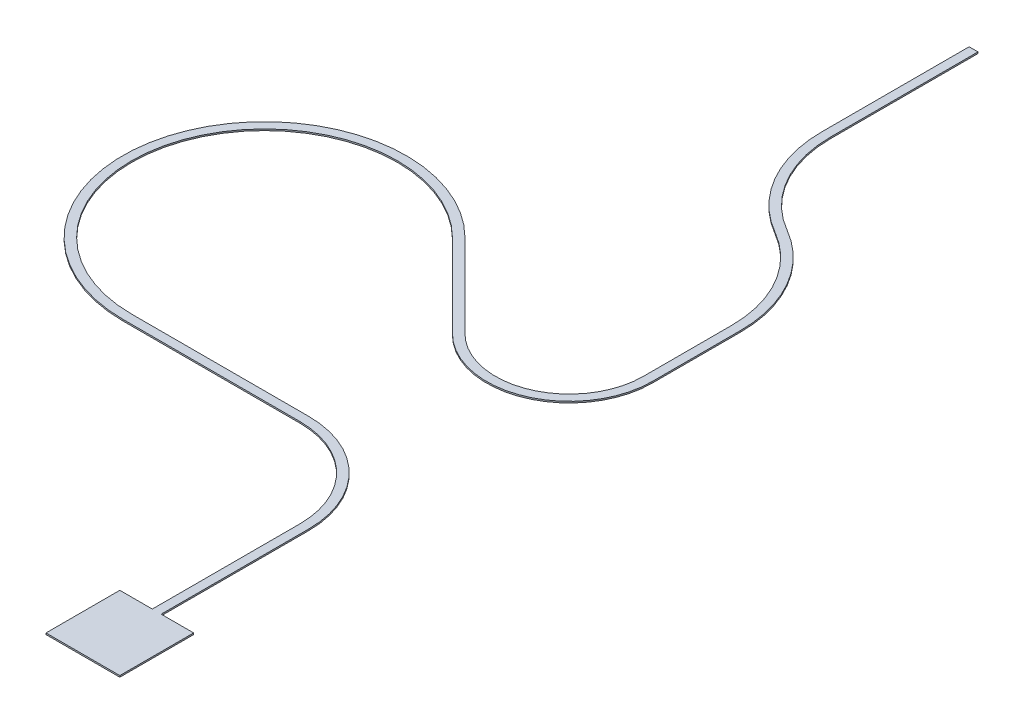
from build123d import *

# Parameters (mm, degrees)
BOSS_EXTRUDE1_DEPTH = 5


with BuildPart() as part:
    # Sketch1 → Boss-Extrude1 (new body)
    with BuildSketch(Plane(origin=(0, 0, 0), x_dir=(1, 0, 0), z_dir=(0, 1, 0))):
        with BuildLine():
            Line((-315, 955), (-915, 955))
            ThreePointArc((-915, 955), (-1330.74578963, 1577.207544564), (-596.801948466, 1723.198051534))
            Line((-596.801948466, 1723.198051534), (-313.959235991, 1440.355339059))
            ThreePointArc((-313.959235991, 1440.355339059), (-8.817976197, 1379.658968688), (164.030662741, 1638.345237792))
            Line((164.030662741, 1638.345237792), (164.030662741, 1938.345237792))
            ThreePointArc((164.030662741, 1938.345237792), (106.421586368, 2153.345237792), (-50.969337259, 2310.736161419))
            ThreePointArc((-50.969337259, 2310.736161419), (-197.379498773, 2457.146322933), (-250.969337259, 2657.146322933))
            Line((-250.969337259, 2657.146322933), (-250.969337259, 3157.146322933))
            Line((-250.969337259, 3157.146322933), (-280.969337259, 3157.146322933))
            Line((-280.969337259, 3157.146322933), (-280.969337259, 2657.146322933))
            ThreePointArc((-280.969337259, 2657.146322933), (-223.360260887, 2442.146322933), (-65.969337259, 2284.755399305))
            ThreePointArc((-65.969337259, 2284.755399305), (80.440824255, 2138.345237792), (134.030662741, 1938.345237792))
            Line((134.030662741, 1938.345237792), (134.030662741, 1638.345237792))
            ThreePointArc((134.030662741, 1638.345237792), (-20.298479168, 1407.375354664), (-292.746032556, 1461.568542495))
            Line((-292.746032556, 1461.568542495), (-575.58874503, 1744.41125497))
            ThreePointArc((-575.58874503, 1744.41125497), (-1358.462175605, 1588.688047535), (-915, 925))
            Line((-915, 925), (-315, 925))
            ThreePointArc((-315, 925), (-102.867965644, 837.132034356), (-15, 625))
            Line((-15, 625), (-15, 125))
            Line((-15, 125), (-125, 125))
            Line((-125, 125), (-125, -125))
            Line((-125, -125), (125, -125))
            Line((125, -125), (125, 125))
            Line((125, 125), (15, 125))
            Line((15, 125), (15, 625))
            ThreePointArc((15, 625), (-81.654762208, 858.345237792), (-315, 955))
        make_face()
    extrude(amount=BOSS_EXTRUDE1_DEPTH)


solid = part.part
